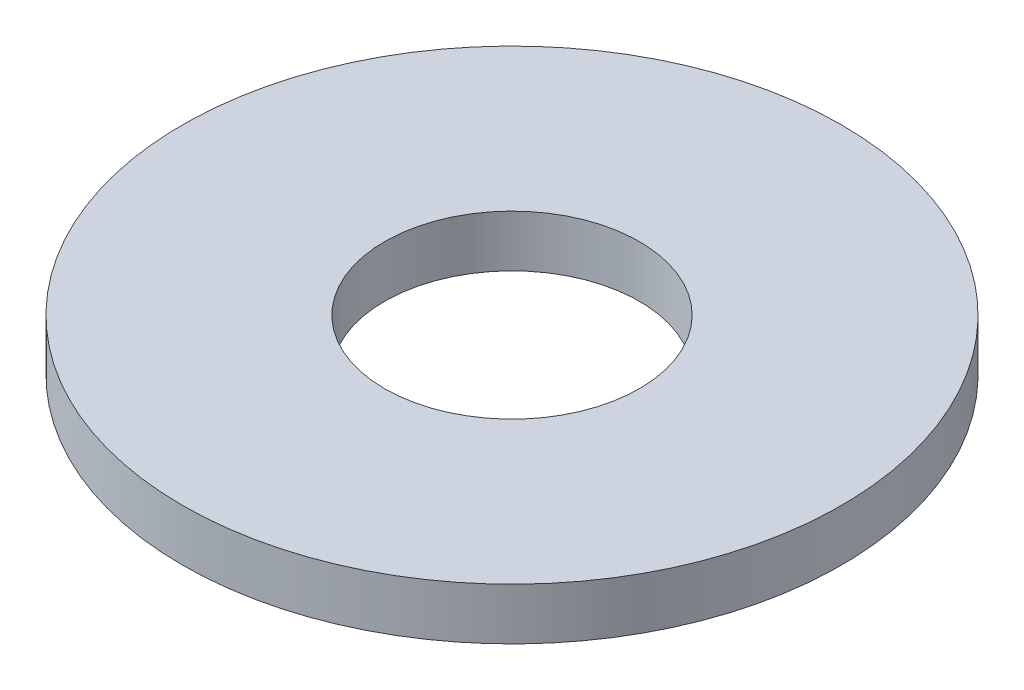
from build123d import *

# Parameters (mm, degrees)
SKETCH1_R           = 8.7376
BOSS_EXTRUDE1_DEPTH = 1.3716
SKETCH5_R           = 3.3782
CUT_EXTRUDE1_DEPTH  = 2.3716


with BuildPart() as part:
    # Sketch1 → Boss-Extrude1 (new body)
    with BuildSketch(Plane(origin=(0, 0, 0), x_dir=(1, 0, 0), z_dir=(0, 1, 0))):
        Circle(SKETCH1_R)
    extrude(amount=BOSS_EXTRUDE1_DEPTH)

    # Sketch5 → Cut-Extrude1 (cut, through all)
    with BuildSketch(Plane(origin=(0, 1.3716, 0), x_dir=(-1, 0, 0), z_dir=(0, 1, 0))):
        Circle(SKETCH5_R)
    extrude(amount=-CUT_EXTRUDE1_DEPTH, mode=Mode.SUBTRACT)


solid = part.part
